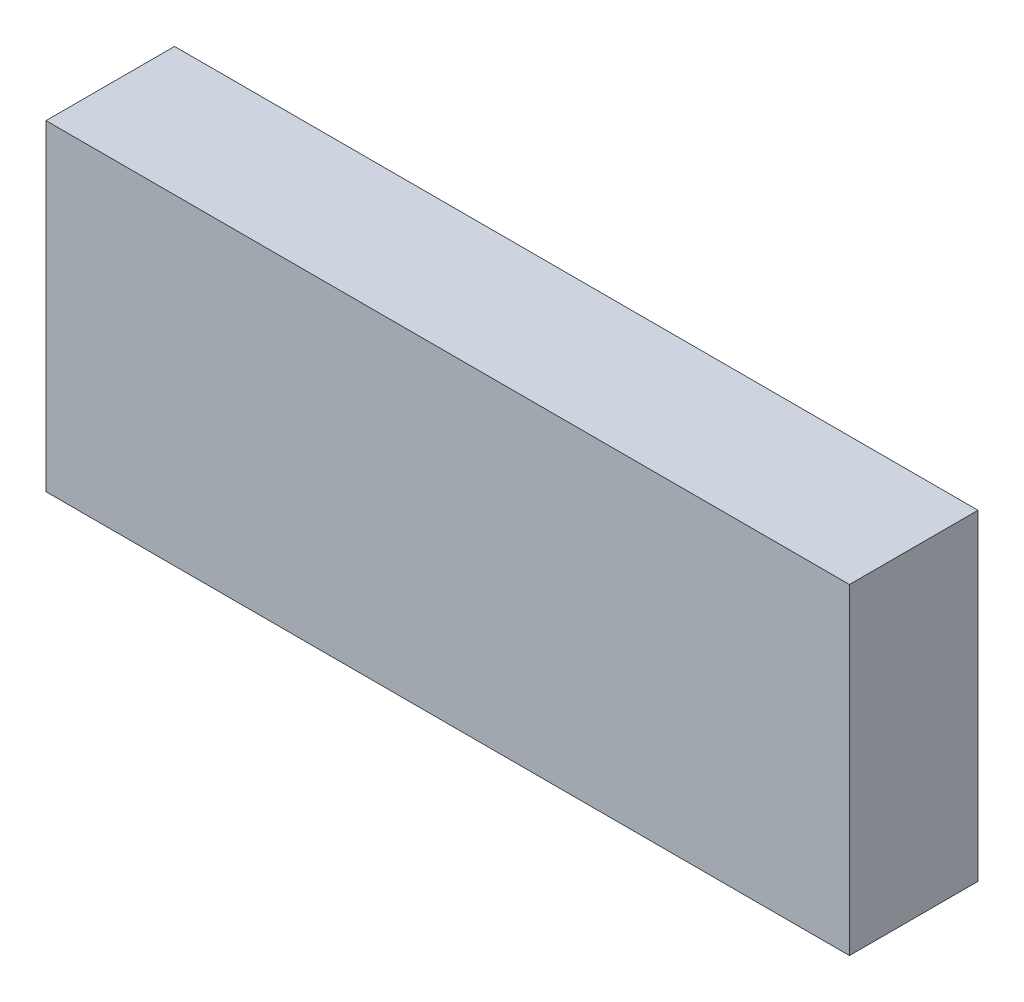
from build123d import *

# Parameters (mm, degrees)
SKETCH1_W           = 25
SKETCH1_H           = 10
BOSS_EXTRUDE1_DEPTH = 4


with BuildPart() as part:
    # Sketch1 → Boss-Extrude1 (new body)
    with BuildSketch(Plane.XY):
        Rectangle(SKETCH1_W, SKETCH1_H)
    extrude(amount=BOSS_EXTRUDE1_DEPTH)


solid = part.part
